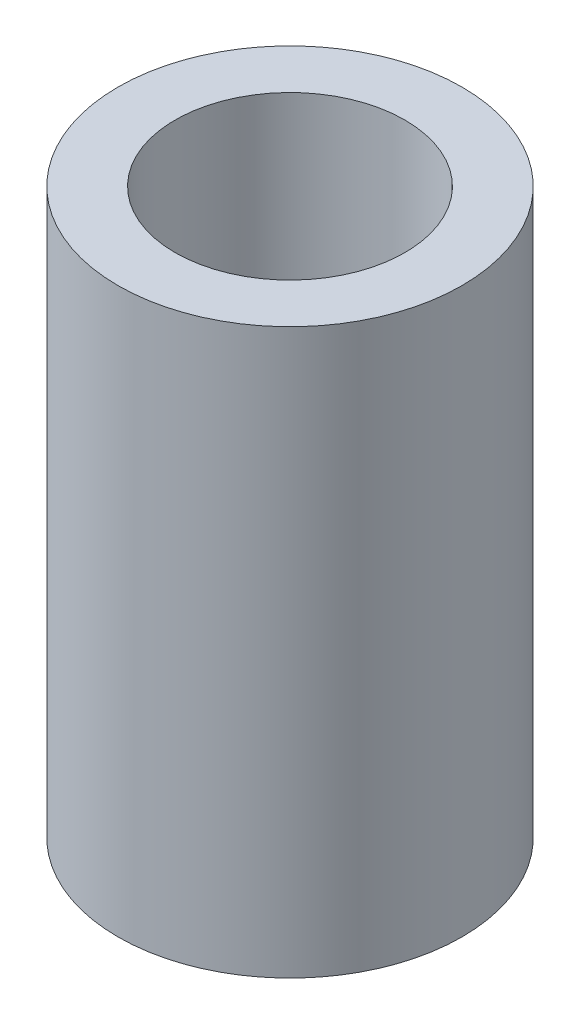
from build123d import *

# Parameters (mm, degrees)
SKETCH1_R           = 25
SKETCH1_R_2         = 16.7
BOSS_EXTRUDE1_DEPTH = 41


with BuildPart() as part:
    # Sketch1 → Boss-Extrude1 (new body, symmetric)
    with BuildSketch(Plane(origin=(0, 0, 0), x_dir=(1, 0, 0), z_dir=(0, 1, 0))):
        Circle(SKETCH1_R)
        Circle(SKETCH1_R_2, mode=Mode.SUBTRACT)
    extrude(amount=BOSS_EXTRUDE1_DEPTH, both=True)


solid = part.part
